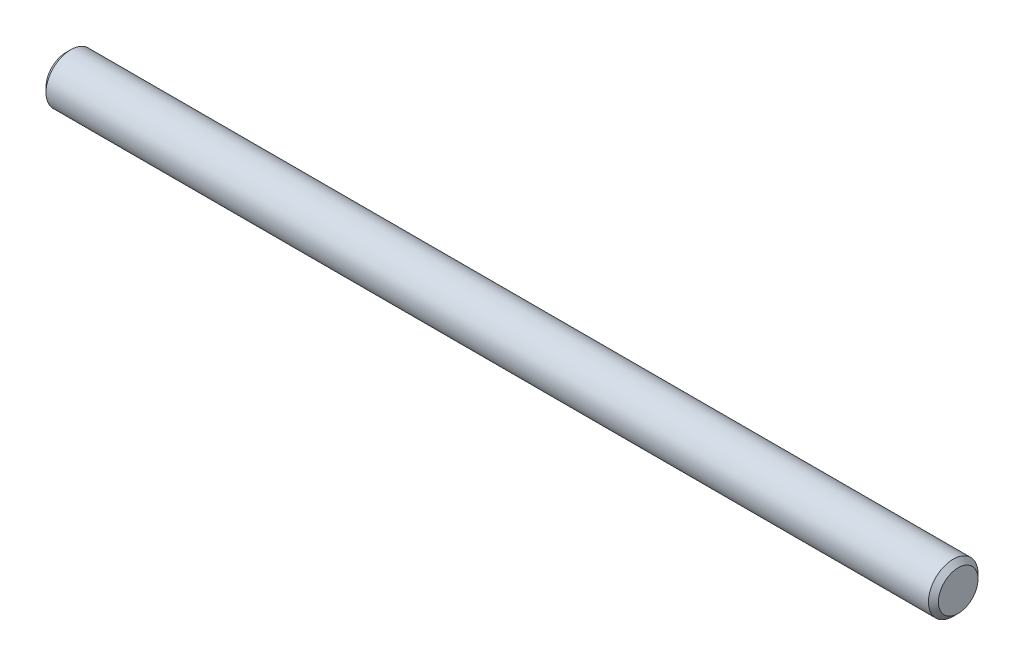
from build123d import *

# Parameters (mm, degrees)
SKETCH1_W     = 36
SKETCH1_H     = 1
CHAMFER1_SIZE = 0.2


with BuildPart() as part:
    # Sketch1 → Revolve1 (revolve)
    with BuildSketch(Plane.XY):
        with Locations((0, 0.5)):
            Rectangle(SKETCH1_W, SKETCH1_H)
    revolve(axis=Axis((-18, 0, 0), (1, 0, 0)))

    # Chamfer1
    chamfer1_edges = [part.edges().sort_by_distance(p)[0] for p in [
        (18, -1, 0),
        (-18, -1, 0),
    ]]
    chamfer(chamfer1_edges, length=CHAMFER1_SIZE)


solid = part.part
